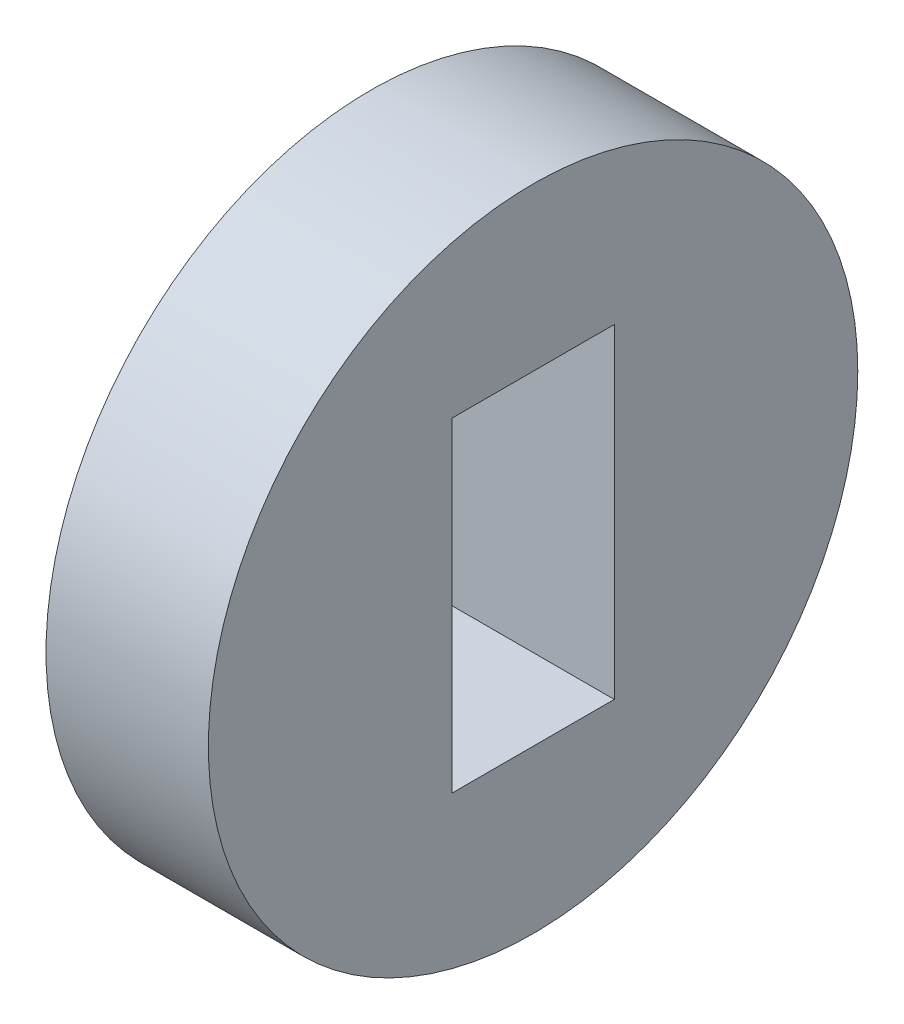
from build123d import *

# Parameters (mm, degrees)
SKETCH1_R           = 6
SKETCH1_R_2         = 3.354101966
BOSS_EXTRUDE1_DEPTH = 3


with BuildPart() as part:
    # Sketch1 → Boss-Extrude1 (new body)
    with BuildSketch(Plane(origin=(0, 0, 0), x_dir=(0, 0, -1), z_dir=(1, 0, 0))):
        with Locations((-33.580329287, -7.15217083)):
            Circle(SKETCH1_R)
        with Locations((-33.580329287, -7.15217083)):
            Circle(SKETCH1_R_2, mode=Mode.SUBTRACT)
        with BuildLine():
            Line((-35.080329287, -4.15217083), (-32.080329287, -4.15217083))
            ThreePointArc((-32.080329287, -4.15217083), (-33.580329287, -3.798068864), (-35.080329287, -4.15217083))
        make_face()
        with BuildLine():
            ThreePointArc((-35.080329287, -4.15217083), (-36.934431253, -7.15217083), (-35.080329287, -10.15217083))
            Line((-35.080329287, -10.15217083), (-35.080329287, -4.15217083))
        make_face()
        with BuildLine():
            Line((-32.080329287, -4.15217083), (-32.080329287, -10.15217083))
            ThreePointArc((-32.080329287, -10.15217083), (-30.727159738, -8.915526587), (-30.22622732, -7.15217083))
            ThreePointArc((-30.22622732, -7.15217083), (-30.727159738, -5.388815073), (-32.080329287, -4.15217083))
        make_face()
        with BuildLine():
            ThreePointArc((-35.080329287, -10.15217083), (-33.580329287, -10.506272796), (-32.080329287, -10.15217083))
            Line((-32.080329287, -10.15217083), (-35.080329287, -10.15217083))
        make_face()
    extrude(amount=BOSS_EXTRUDE1_DEPTH)


solid = part.part
